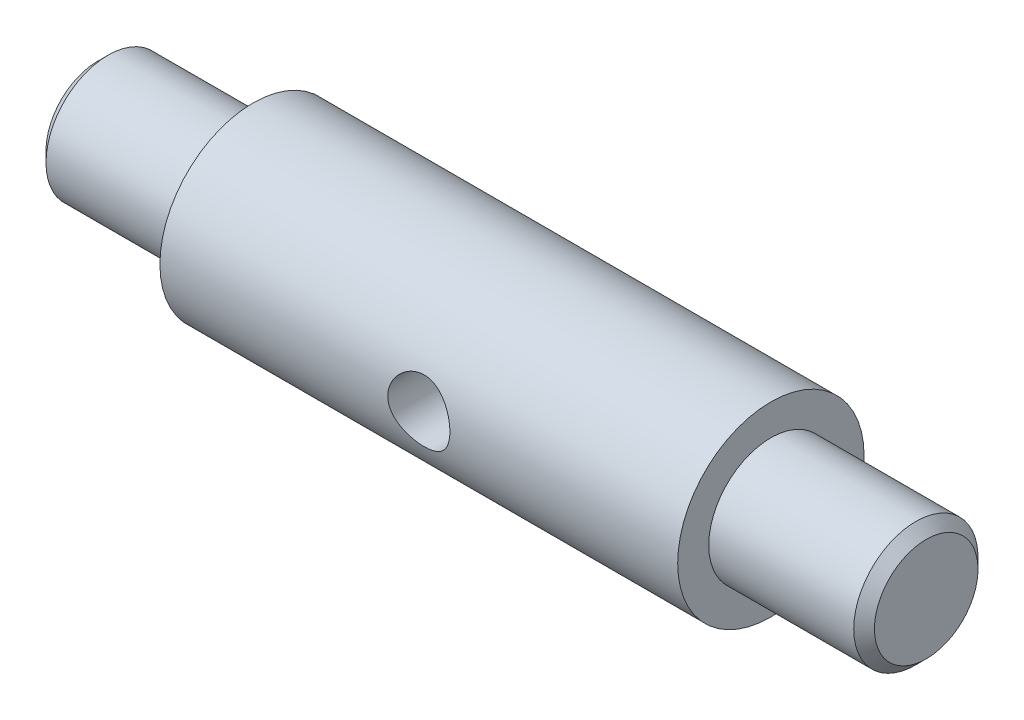
from build123d import *

# Parameters (mm, degrees)
SKETCH2_R                    = 3
CUT_EXTRUDE1_DEPTH           = 10
CUT_EXTRUDE1_DEPTH_BACK      = 10
CHAMFER1_SIZE                = 1
F_6_0_6_DIAMETER_HOLE1_D     = 6
F_6_0_6_DIAMETER_HOLE1_DEPTH = 45
F_6_0_6_DIAMETER_HOLE1_TIP   = 1.802581857


with BuildPart() as part:
    # Sketch1 → Revolve2 (revolve)
    with BuildSketch(Plane.XY):
        Polygon((0, 0), (80, 0), (80, 6), (65, 6), (65, 9), (15, 9), (15, 6), (0, 6), align=None)
    revolve(axis=Axis((0, 0, 0), (1, 0, 0)))

    # Sketch2 → Cut-Extrude1 (cut, two sides)
    with BuildSketch(Plane.XY) as cut_extrude1_sk:
        with Locations((40, 0)):
            Circle(SKETCH2_R)
    extrude(amount=CUT_EXTRUDE1_DEPTH, mode=Mode.SUBTRACT)
    extrude(cut_extrude1_sk.sketch, amount=-CUT_EXTRUDE1_DEPTH_BACK, mode=Mode.SUBTRACT)

    # Chamfer1
    chamfer1_edges = [part.edges().sort_by_distance(p)[0] for p in [
        (0, -6, 0),
        (80, -6, 0),
    ]]
    chamfer(chamfer1_edges, length=CHAMFER1_SIZE)

    # Ø6.0 (6) Diameter Hole1
    with Locations(Plane.ZY):
        with Locations((0, 0)):
            Hole(F_6_0_6_DIAMETER_HOLE1_D / 2, depth=F_6_0_6_DIAMETER_HOLE1_DEPTH)
            with Locations((0, 0, -(F_6_0_6_DIAMETER_HOLE1_DEPTH + F_6_0_6_DIAMETER_HOLE1_TIP / 2))):  # 118° drill point
                Cone(0, F_6_0_6_DIAMETER_HOLE1_D / 2, F_6_0_6_DIAMETER_HOLE1_TIP, mode=Mode.SUBTRACT)


solid = part.part
